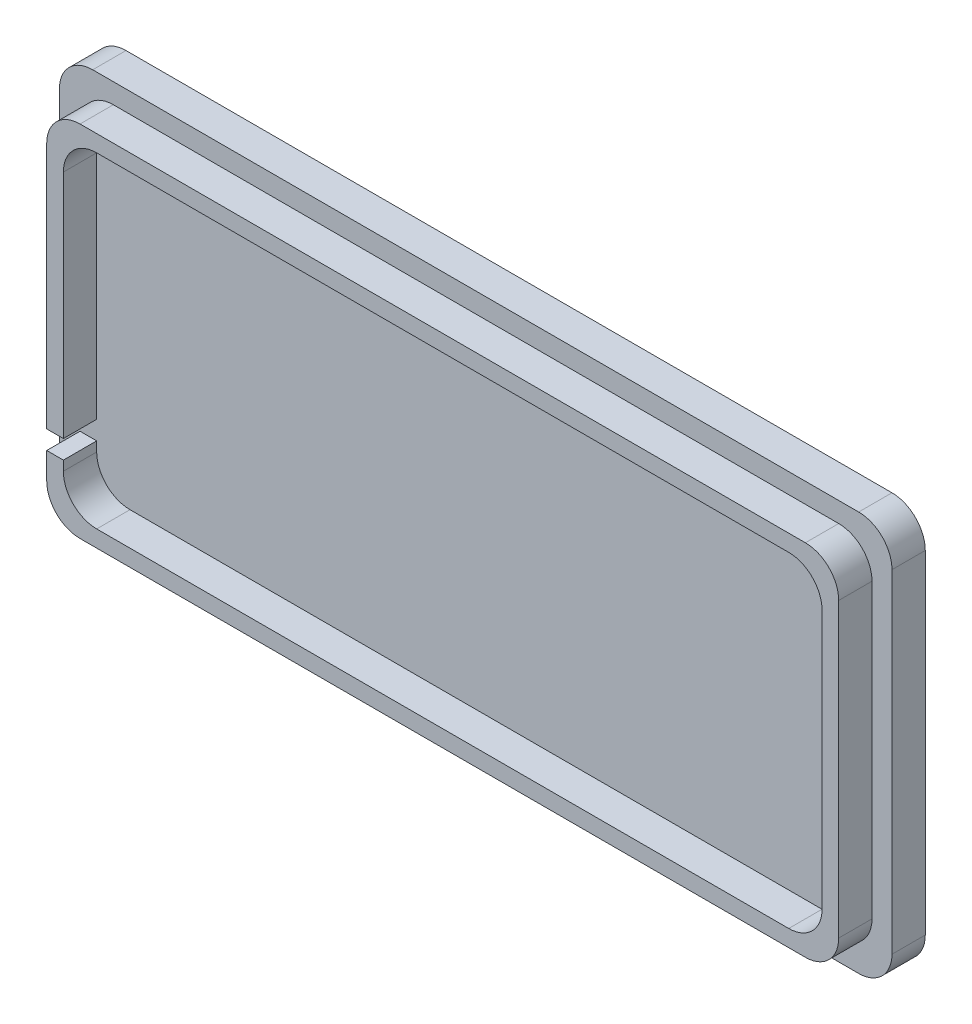
from build123d import *

# Parameters (mm, degrees)
SKETCH2_W           = 302.006
SKETCH2_H           = 136.906
BOSS_EXTRUDE1_DEPTH = 12.7
SKETCH3_W           = 317.5
SKETCH3_H           = 152.4
BOSS_EXTRUDE2_DEPTH = 12.7
SKETCH4_W           = 289.306
SKETCH4_H           = 124.206
CUT_EXTRUDE1_DEPTH  = 12.7
CUT_EXTRUDE3_REACH  = 311.626
FILLET1_R           = 12.7


with BuildPart() as part:
    # Sketch2 → Boss-Extrude1 (new body)
    with BuildSketch(Plane.XY):
        Rectangle(SKETCH2_W, SKETCH2_H)
    extrude(amount=BOSS_EXTRUDE1_DEPTH)

    # Sketch3 → Boss-Extrude2 (add)
    with BuildSketch(Plane(origin=(0, 0, 0), x_dir=(-1, 0, 0), z_dir=(0, 0, -1))):
        with Locations((0.127, -0.127)):
            Rectangle(SKETCH3_W, SKETCH3_H)
    extrude(amount=BOSS_EXTRUDE2_DEPTH)

    # Sketch4 → Cut-Extrude1 (cut)
    with BuildSketch(Plane.XY.offset(12.7)):
        Rectangle(SKETCH4_W, SKETCH4_H)
    extrude(amount=-CUT_EXTRUDE1_DEPTH, mode=Mode.SUBTRACT)

    # Sketch5 → Cut-Extrude3 (cut, up to next)
    with BuildSketch(Plane.ZY.offset(151.003), mode=Mode.PRIVATE) as cut_extrude3_sk1:
        with BuildLine():
            Line((12.7, -45.72), (0, -45.72))
            Line((0, -45.72), (0, -38.608))
            Line((0, -38.608), (12.7, -38.608))
            ThreePointArc((12.7, -38.608), (16.256, -42.164), (12.7, -45.72))
        make_face()
    cut_extrude3_tool1 = extrude(cut_extrude3_sk1.sketch, amount=-CUT_EXTRUDE3_REACH, mode=Mode.PRIVATE) & part.part
    add(cut_extrude3_tool1.solids().sort_by_distance((-151.003, -42.164, 7.766768))[0], mode=Mode.SUBTRACT)

    # Fillet1
    fillet1_edges = [part.edges().sort_by_distance(p)[0] for p in [
        (-158.877, -76.327, -6.35),
        (-158.877, 76.073, -6.35),
        (158.623, 76.073, -6.35),
        (158.623, -76.327, -6.35),
        (-144.653, 62.103, 6.35),
        (144.653, 62.103, 6.35),
        (144.653, -62.103, 6.35),
        (-144.653, -62.103, 6.35),
        (-151.003, 68.453, 6.35),
        (151.003, 68.453, 6.35),
        (151.003, -68.453, 6.35),
        (-151.003, -68.453, 6.35),
    ]]
    fillet(fillet1_edges, radius=FILLET1_R)


solid = part.part
